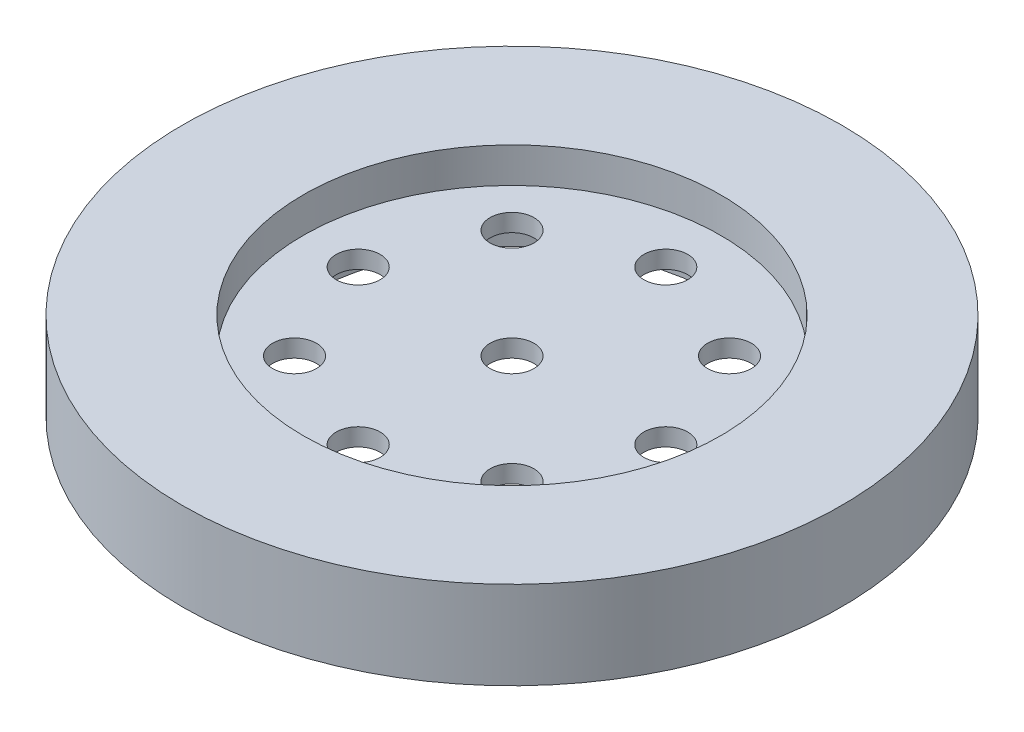
from build123d import *

# Parameters (mm, degrees)
SKETCH1_R           = 75
SKETCH1_R_2         = 43
BOSS_EXTRUDE1_DEPTH = 20
SKETCH2_R           = 43
BOSS_EXTRUDE2_DEPTH = 20
SKETCH3_R           = 47.5
CUT_EXTRUDE1_DEPTH  = 8
SKETCH6_R           = 5
CUT_EXTRUDE4_DEPTH  = 13
SKETCH4_R           = 47.5
CUT_EXTRUDE2_DEPTH  = 8
SKETCH5_R           = 3
SKETCH5_R_2         = 5
CUT_EXTRUDE3_DEPTH  = 13


with BuildPart() as part:
    # Sketch1 → Boss-Extrude1 (new body)
    with BuildSketch(Plane(origin=(0, 0, 0), x_dir=(1, 0, 0), z_dir=(0, 1, 0))):
        Circle(SKETCH1_R)
        Circle(SKETCH1_R_2, mode=Mode.SUBTRACT)
    extrude(amount=BOSS_EXTRUDE1_DEPTH)

    # Sketch2 → Boss-Extrude2 (add)
    with BuildSketch(Plane(origin=(0, 20, 0), x_dir=(1, 0, 0), z_dir=(0, 1, 0))):
        Circle(SKETCH2_R)
    extrude(amount=-BOSS_EXTRUDE2_DEPTH)

    # Sketch3 → Cut-Extrude1 (cut)
    with BuildSketch(Plane(origin=(0, 20, 0), x_dir=(1, 0, 0), z_dir=(0, 1, 0))):
        Circle(SKETCH3_R)
    extrude(amount=-CUT_EXTRUDE1_DEPTH, mode=Mode.SUBTRACT)

    # Sketch6 → Cut-Extrude4 (cut, through all)
    with BuildSketch(Plane(origin=(0, 12, 0), x_dir=(1, 0, 0), z_dir=(0, 1, 0))):
        Circle(SKETCH6_R)
    extrude(amount=-CUT_EXTRUDE4_DEPTH, mode=Mode.SUBTRACT)

    # Sketch4 → Cut-Extrude2 (cut)
    with BuildSketch(Plane.XZ):
        Circle(SKETCH4_R)
    extrude(amount=-CUT_EXTRUDE2_DEPTH, mode=Mode.SUBTRACT)

    # Sketch5 → Cut-Extrude3 (cut, through all)
    with BuildSketch(Plane(origin=(0, 12, 0), x_dir=(1, 0, 0), z_dir=(0, 1, 0))):
        Circle(SKETCH5_R)
        with Locations((0, 35)):
            Circle(SKETCH5_R_2)
        with Locations((24.748737342, 24.748737342)):
            Circle(SKETCH5_R_2)
        with Locations((35, 0)):
            Circle(SKETCH5_R_2)
        with Locations((24.748737342, -24.748737342)):
            Circle(SKETCH5_R_2)
        with Locations((0, -35)):
            Circle(SKETCH5_R_2)
        with Locations((-24.748737342, -24.748737342)):
            Circle(SKETCH5_R_2)
        with Locations((-35, 0)):
            Circle(SKETCH5_R_2)
        with Locations((-24.748737342, 24.748737342)):
            Circle(SKETCH5_R_2)
    extrude(amount=-CUT_EXTRUDE3_DEPTH, mode=Mode.SUBTRACT)


solid = part.part
